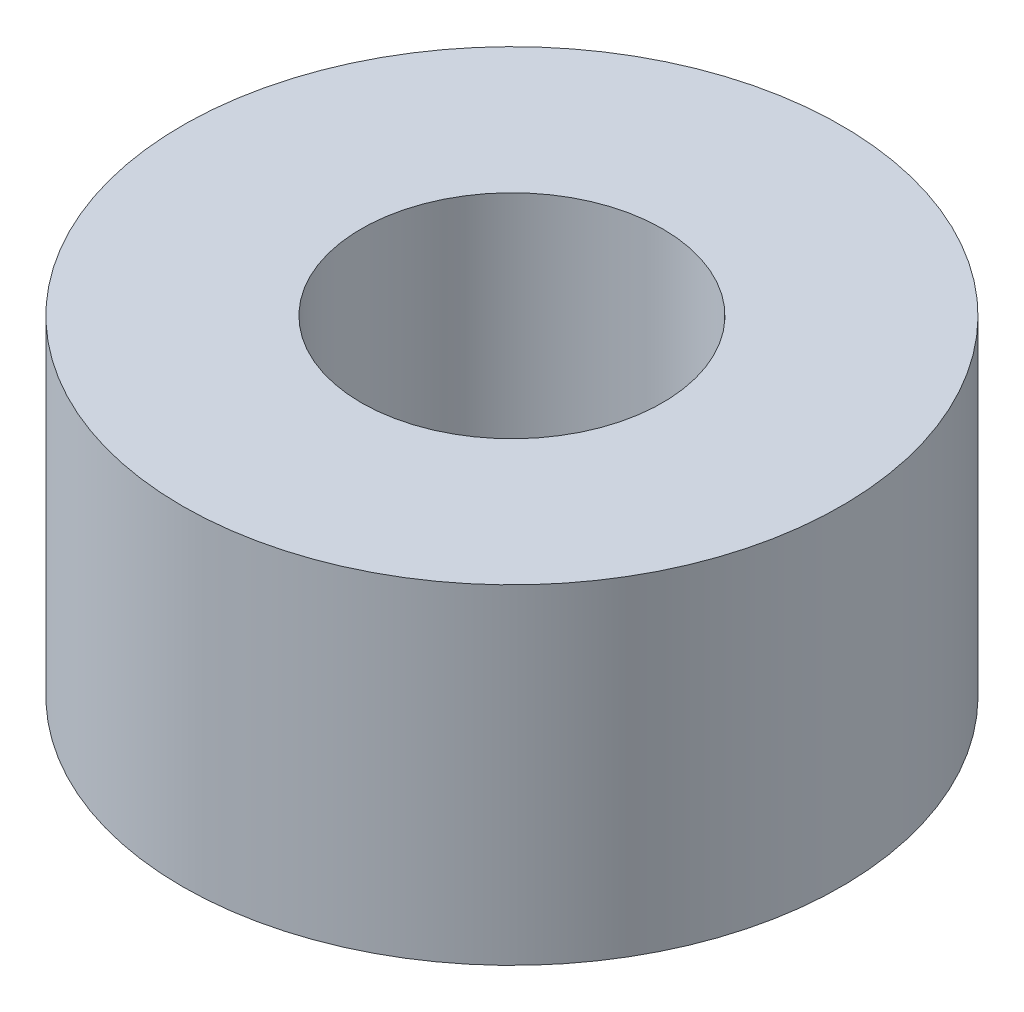
from build123d import *

# Parameters (mm, degrees)
SKETCH1_R           = 3.5
SKETCH1_R_2         = 1.6
BOSS_EXTRUDE1_DEPTH = 3.5


with BuildPart() as part:
    # Sketch1 → Boss-Extrude1 (new body)
    with BuildSketch(Plane(origin=(0, 0, 0), x_dir=(1, 0, 0), z_dir=(0, 1, 0))):
        Circle(SKETCH1_R)
        Circle(SKETCH1_R_2, mode=Mode.SUBTRACT)
    extrude(amount=BOSS_EXTRUDE1_DEPTH)


solid = part.part
